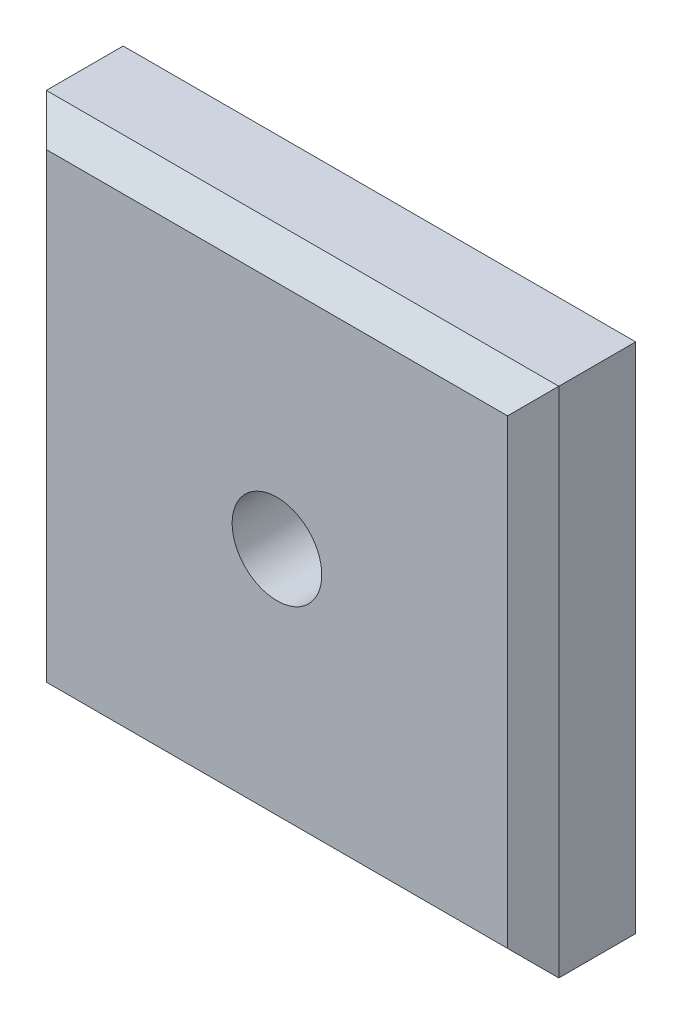
from build123d import *

# Parameters (mm, degrees)
SKETCH1_W                       = 40
SKETCH1_H                       = 40
BOSS_EXTRUDE1_DEPTH             = 10
M8X1_0_TAPPED_HOLE1_D           = 7
M8X1_0_TAPPED_HOLE1_CSINK_D     = 8.05
M8X1_0_TAPPED_HOLE1_CSINK_ANGLE = 90
CHAMFER1_SIZE                   = 2


with BuildPart() as part:
    # Sketch1 → Boss-Extrude1 (new body)
    with BuildSketch(Plane.XY):
        Rectangle(SKETCH1_W, SKETCH1_H)
    extrude(amount=BOSS_EXTRUDE1_DEPTH)

    # M8x1.0 Tapped Hole1 (through all)
    with Locations(Plane(origin=(0, 0, 0), x_dir=(-1, 0, 0), z_dir=(0, 0, -1))):
        with Locations((0, 0)):
            CounterSinkHole(M8X1_0_TAPPED_HOLE1_D / 2, M8X1_0_TAPPED_HOLE1_CSINK_D / 2, counter_sink_angle=M8X1_0_TAPPED_HOLE1_CSINK_ANGLE)

    # Chamfer1
    chamfer1_edges = [part.edges().sort_by_distance(p)[0] for p in [
        (-20, 0, 10),
        (0, -20, 10),
        (20, 0, 10),
        (0, -20, 0),
        (-20, 0, 0),
        (0, 20, 0),
        (20, 0, 0),
        (0, 20, 10),
    ]]
    chamfer(chamfer1_edges, length=CHAMFER1_SIZE)


solid = part.part
